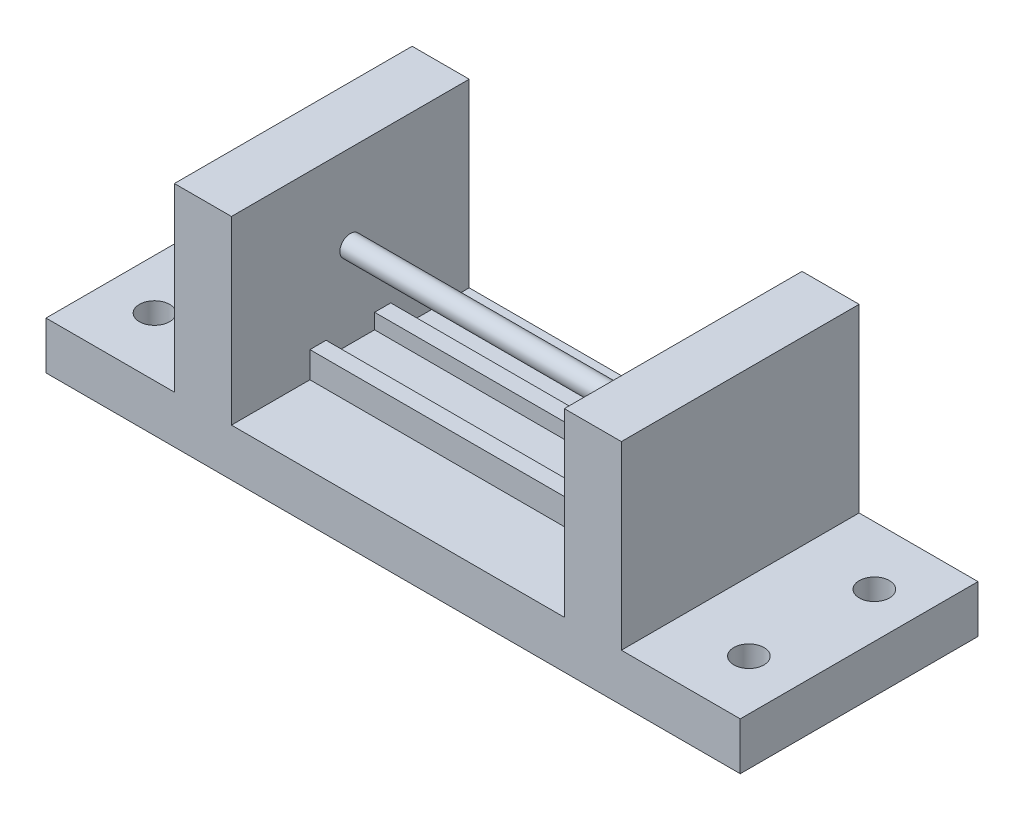
from build123d import *

# Parameters (mm, degrees)
SKETCH1_W           = 146
SKETCH1_H           = 50
BOSS_EXTRUDE1_DEPTH = 10
SKETCH2_R           = 3.175
CUT_EXTRUDE1_DEPTH  = 10
SKETCH3_W           = 12
SKETCH3_H           = 50
BOSS_EXTRUDE2_DEPTH = 38
SKETCH4_R           = 2.2
BOSS_EXTRUDE3_DEPTH = 82
SKETCH5_W           = 70
SKETCH5_H           = 17
BOSS_EXTRUDE4_DEPTH = 5.5
SKETCH6_W           = 70
SKETCH6_H           = 10.2
CUT_EXTRUDE2_DEPTH  = 3.2


with BuildPart() as part:
    # Sketch1 → Boss-Extrude1 (new body)
    with BuildSketch(Plane(origin=(0, 0, 0), x_dir=(1, 0, 0), z_dir=(0, 1, 0))):
        with Locations((73, -25)):
            Rectangle(SKETCH1_W, SKETCH1_H)
    extrude(amount=BOSS_EXTRUDE1_DEPTH)

    # Sketch2 → Cut-Extrude1 (cut)
    with BuildSketch(Plane(origin=(0, 10, 0), x_dir=(1, 0, 0), z_dir=(0, 1, 0))):
        with Locations((9.5, -12.3)):
            Circle(SKETCH2_R)
        with Locations((10.5, -37.680307327)):
            Circle(SKETCH2_R)
    cut_extrude1 = extrude(amount=-CUT_EXTRUDE1_DEPTH, mode=Mode.SUBTRACT)

    # Mirror1: Cut-Extrude1 across plane
    add(cut_extrude1.mirror(Plane.ZY.offset(-73)), mode=Mode.SUBTRACT)

    # Sketch3 → Boss-Extrude2 (add)
    with BuildSketch(Plane(origin=(0, 10, 0), x_dir=(1, 0, 0), z_dir=(0, 1, 0))):
        with Locations((115, -25)):
            Rectangle(SKETCH3_W, SKETCH3_H)
        with Locations((33, -25)):
            Rectangle(SKETCH3_W, SKETCH3_H)
    extrude(amount=BOSS_EXTRUDE2_DEPTH)

    # Sketch4 → Boss-Extrude3 (add)
    with BuildSketch(Plane(origin=(121, 0, 0), x_dir=(0, 0, -1), z_dir=(1, 0, 0))):
        with Locations((-25, 30.2)):
            Circle(SKETCH4_R)
    extrude(amount=-BOSS_EXTRUDE3_DEPTH)

    # Sketch5 → Boss-Extrude4 (add)
    with BuildSketch(Plane(origin=(0, 10, 0), x_dir=(1, 0, 0), z_dir=(0, 1, 0))):
        with Locations((74, -25)):
            Rectangle(SKETCH5_W, SKETCH5_H)
    extrude(amount=BOSS_EXTRUDE4_DEPTH)

    # Sketch6 → Cut-Extrude2 (cut)
    with BuildSketch(Plane(origin=(0, 15.5, 0), x_dir=(1, 0, 0), z_dir=(0, 1, 0))):
        with Locations((74, -25)):
            Rectangle(SKETCH6_W, SKETCH6_H)
    extrude(amount=-CUT_EXTRUDE2_DEPTH, mode=Mode.SUBTRACT)


solid = part.part
